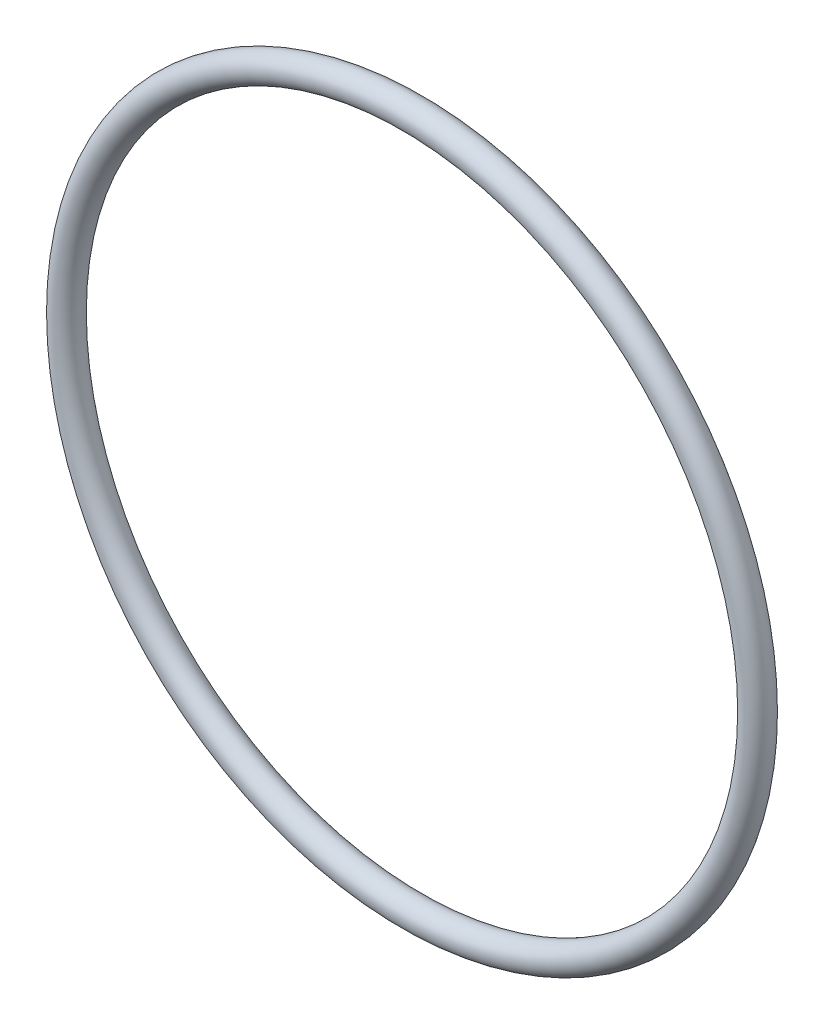
from build123d import *

# Parameters (mm, degrees)
SKETCH1_R = 1.3081


with BuildPart() as part:
    # Sketch1 → Revolve1 (revolve)
    with BuildSketch(Plane(origin=(0, 0, 0), x_dir=(0, -1, 0), z_dir=(1, 0, 0))):
        with Locations((32.1056, 0)):
            Circle(SKETCH1_R)
    revolve(axis=Axis((0, 0, 1.3081), (0, 0, -1)))


solid = part.part
